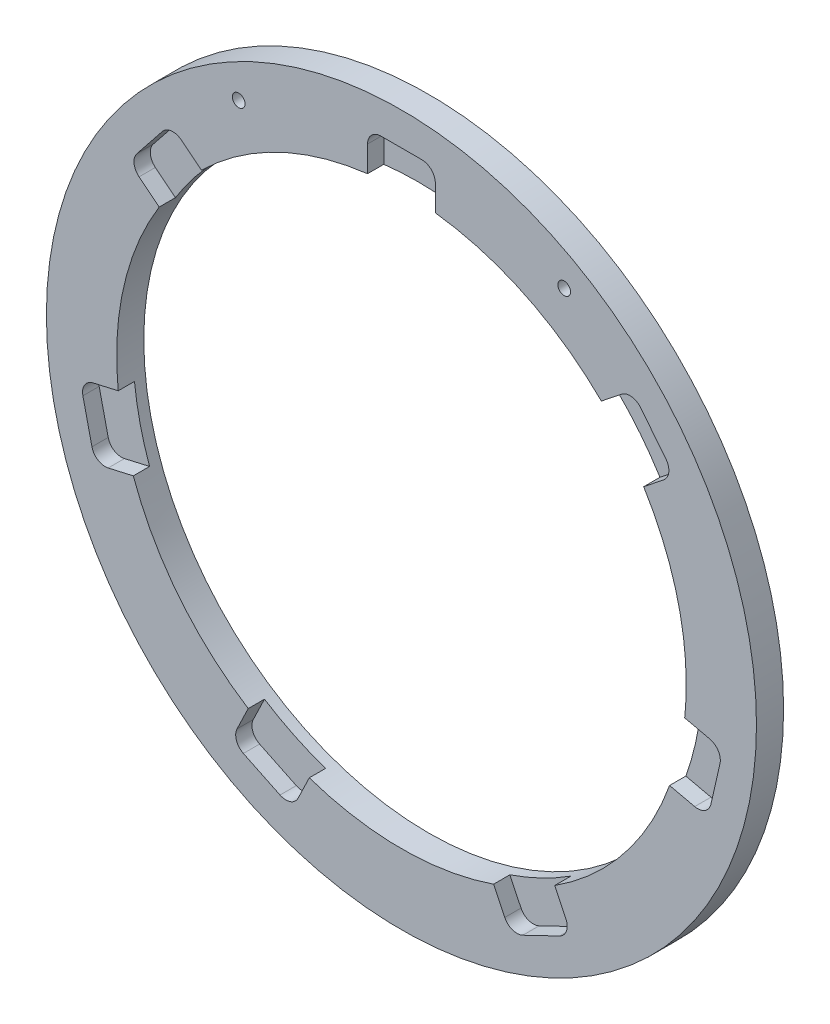
from build123d import *

# Parameters (mm, degrees)
BOSS_EXTRUDE1_DEPTH       = 0.762
BOSS_EXTRUDE1_DEPTH_BACK  = 1.778
SKETCH1_W                 = 74.549
SKETCH1_H                 = 74.549
SKETCH1_R                 = 26.67
SKETCH2_R                 = 3.302
CUT_EXTRUDE1_DEPTH        = 53.775262202
MIRROR2_COPY_1_SKETCH_R   = 3.302
MIRROR2_COPY_1_DEPTH      = 53.775262202
MIRROR2_COPY_2_SKETCH_R   = 3.302
MIRROR2_COPY_2_DEPTH      = 53.775262202
SKETCH14_OUTSIDE_W        = 97.642
SKETCH14_OUTSIDE_H        = 97.642
SKETCH14_OUTSIDE_R        = 33.2486
CUT_EXTRUDE6_DEPTH        = 53.775262202
SKETCH15_W                = 6.35
SKETCH15_H                = 8.89
CUT_EXTRUDE7_DEPTH        = 1.524
FILLET2_R                 = 1.27
CIRPATTERN2_COUNT         = 7
FILLET2_OF_CIRPATTERN2_R  = 1.27
SKETCH16_R                = 0.0127
CUT_EXTRUDE8_DEPTH        = 48.089175018
F_0_80_TAPPED_HOLE3_D     = 1.19126
F_0_80_TAPPED_HOLE3_DEPTH = 4.064
F_0_80_TAPPED_HOLE3_TIP   = 0.357890611


with BuildPart() as part:
    # Sketch1 → Boss-Extrude1 (new, two sides: drawn at the far end of the back side and taken through both)
    with BuildSketch(Plane.XY.offset(-BOSS_EXTRUDE1_DEPTH_BACK)):
        Rectangle(SKETCH1_W, SKETCH1_H)
        Circle(SKETCH1_R, mode=Mode.SUBTRACT)
    extrude(amount=BOSS_EXTRUDE1_DEPTH + BOSS_EXTRUDE1_DEPTH_BACK)

    # Sketch2 → Cut-Extrude1 (cut, through all)
    with BuildSketch(Plane.XY.offset(0.762)):
        with Locations((-31.75, 31.75)):
            Circle(SKETCH2_R)
    cut_extrude1 = extrude(amount=-CUT_EXTRUDE1_DEPTH, mode=Mode.SUBTRACT)

    # Mirror1: Cut-Extrude1 across plane
    add(cut_extrude1.mirror(Plane(origin=(0, 0, 0), x_dir=(0, 0, 1), z_dir=(1, 0, 0))), mode=Mode.SUBTRACT)

    # Mirror2 copy 1 sketch → Mirror2 copy 1 (cut, through all)
    with BuildSketch(Plane(origin=(0, 0, 0.762), x_dir=(-1, 0, 0), z_dir=(0, 0, 1))):
        with Locations((-31.75, 31.75)):
            Circle(MIRROR2_COPY_1_SKETCH_R)
    extrude(amount=-MIRROR2_COPY_1_DEPTH, mode=Mode.SUBTRACT)

    # Mirror2 copy 2 sketch → Mirror2 copy 2 (cut, through all)
    with BuildSketch(Plane.XY.offset(0.762)):
        with Locations((-31.75, -31.75)):
            Circle(MIRROR2_COPY_2_SKETCH_R)
    extrude(amount=-MIRROR2_COPY_2_DEPTH, mode=Mode.SUBTRACT)

    # Sketch14 outside → Cut-Extrude6 (cut, through all)
    with BuildSketch(Plane.XY.offset(0.762)):
        Rectangle(SKETCH14_OUTSIDE_W, SKETCH14_OUTSIDE_H)
        Circle(SKETCH14_OUTSIDE_R, mode=Mode.SUBTRACT)
    extrude(amount=-CUT_EXTRUDE6_DEPTH, mode=Mode.SUBTRACT)

    # Sketch15 → Cut-Extrude7 (cut)
    with BuildSketch(Plane.XY.offset(0.762)):
        with Locations((0, 25.7175)):
            Rectangle(SKETCH15_W, SKETCH15_H)
    cut_extrude7 = extrude(amount=-CUT_EXTRUDE7_DEPTH, mode=Mode.SUBTRACT)

    # Fillet2
    fillet2_edges = [part.edges().sort_by_distance(p)[0] for p in [
        (3.175, 30.1625, 0),
        (-3.175, 30.1625, 0),
    ]]
    fillet(fillet2_edges, radius=FILLET2_R)

    # CirPattern2: Cut-Extrude7 ×7 about axis
    cirpattern2_axis = Axis((0, 0, -1.778), (0, 0, 1))
    for i in range(1, CIRPATTERN2_COUNT):
        add(cut_extrude7.rotate(cirpattern2_axis, i * 360 / CIRPATTERN2_COUNT), mode=Mode.SUBTRACT)

    # Fillet2 of CirPattern2
    fillet2_of_cirpattern2_edges = [part.edges().sort_by_distance(p)[0] for p in [
        (-21.602411969, 21.288326105, 0),
        (-25.561572211, 16.323696192, 0),
        (-30.112767116, -3.616391549, 0),
        (-28.699759186, -9.807183792, 0),
        (-15.947594437, -25.797892606, 0),
        (-10.226442126, -28.55305435, 0),
        (10.226442126, -28.55305435, 0),
        (15.947594437, -25.797892606, 0),
        (28.699759186, -9.807183792, 0),
        (30.112767116, -3.616391549, 0),
        (25.561572211, 16.323696192, 0),
        (21.602411969, 21.288326105, 0),
    ]]
    fillet(fillet2_of_cirpattern2_edges, radius=FILLET2_OF_CIRPATTERN2_R)

    # Sketch16 → Cut-Extrude8 (cut, through all)
    with BuildSketch(Plane.XY.offset(0.762)):
        with Locations((-15.24, 26.396454307)):
            Circle(SKETCH16_R)
    cut_extrude8 = extrude(amount=-CUT_EXTRUDE8_DEPTH, mode=Mode.SUBTRACT)

    # Mirror4: Cut-Extrude8 across plane
    add(cut_extrude8.mirror(Plane(origin=(0, 0, 0), x_dir=(0, 0, 1), z_dir=(1, 0, 0))), mode=Mode.SUBTRACT)

    # 0-80 Tapped Hole3
    with Locations(Plane.XY.offset(0.762)):
        with Locations((-15.24, 26.396454307), (15.24, 26.396454307)):
            Hole(F_0_80_TAPPED_HOLE3_D / 2, depth=F_0_80_TAPPED_HOLE3_DEPTH)
            with Locations((0, 0, -(F_0_80_TAPPED_HOLE3_DEPTH + F_0_80_TAPPED_HOLE3_TIP / 2))):  # 118° drill point
                Cone(0, F_0_80_TAPPED_HOLE3_D / 2, F_0_80_TAPPED_HOLE3_TIP, mode=Mode.SUBTRACT)


solid = part.part
